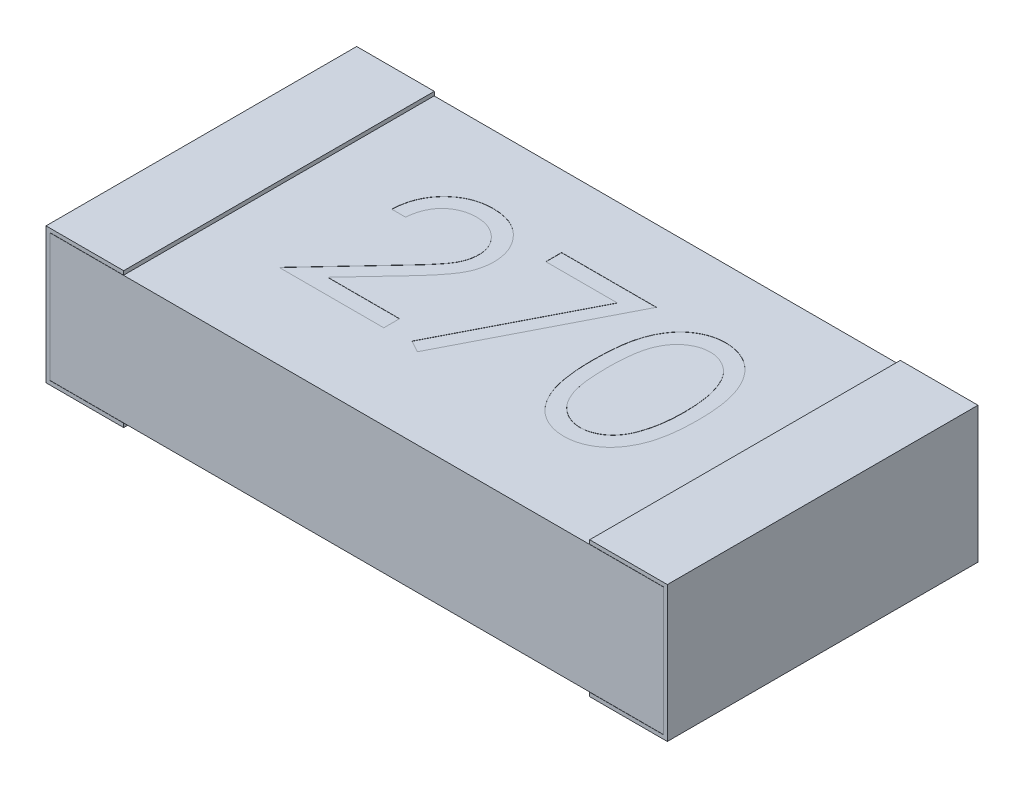
from build123d import *

# Parameters (mm, degrees)
SKETCH1_W           = 3.2
SKETCH1_H           = 1.6
BOSS_EXTRUDE1_DEPTH = 0.7
SKETCH2_W           = 2.4
SKETCH2_H           = 0.021
CUT_EXTRUDE1_DEPTH  = 4.645545227
CUT_EXTRUDE2_DEPTH  = 4.645545227
CUT_EXTRUDE3_DEPTH  = 0.001


with BuildPart() as part:
    # Sketch1 → Boss-Extrude1 (new body)
    with BuildSketch(Plane(origin=(0, 0, 0), x_dir=(1, 0, 0), z_dir=(0, 1, 0))):
        with Locations((1.6, 0.8)):
            Rectangle(SKETCH1_W, SKETCH1_H)
    extrude(amount=BOSS_EXTRUDE1_DEPTH)

    # Sketch2 → Cut-Extrude1 (cut, through all)
    with BuildSketch(Plane.XY):
        with Locations((1.6, 0.6895)):
            Rectangle(SKETCH2_W, SKETCH2_H)
        with Locations((1.6, 0.0105)):
            Rectangle(SKETCH2_W, SKETCH2_H)
    extrude(amount=-CUT_EXTRUDE1_DEPTH, mode=Mode.SUBTRACT)

    # Sketch5 → Cut-Extrude2 (cut, through all)
    with BuildSketch(Plane.XY):
        Polygon((0.02, 0.02), (0.4, 0.02), (0.4, 0.021), (0.021, 0.021), (0.021, 0.679), (0.4, 0.679), (0.4, 0.68), (0.02, 0.68), align=None)
        Polygon((3.179, 0.021), (2.8, 0.021), (2.8, 0.02), (3.18, 0.02), (3.18, 0.68), (2.8, 0.68), (2.8, 0.679), (3.179, 0.679), align=None)
    extrude(amount=-CUT_EXTRUDE2_DEPTH, mode=Mode.SUBTRACT)


with BuildPart() as cut_extrude2_piece_1:
    # of the separate pieces the step leaves, piece 1, a body of its own (cut_extrude2_pieces)
    add(part.part.solids().sort_by_distance((3.179, 0.679, 0))[0])

    # Sketch6 → Cut-Extrude3 (cut)
    with BuildSketch(Plane(origin=(0, 0.679, 0), x_dir=(1, 0, 0), z_dir=(0, 1, 0))):
        with BuildLine():
            Line((0.866030363, 0.985569169), (0.794796388, 0.985569169))
            add(Edge.make_bspline(
                [(0.794796388, 0.985569169), (0.795260653, 0.995019531), (0.796172458, 1.013579791), (0.800442445, 1.040640748), (0.806552251, 1.066506747), (0.815190848, 1.090970102), (0.825919236, 1.114247118), (0.838784796, 1.136245336), (0.854023402, 1.156880837), (0.871306, 1.175962325), (0.890076745, 1.193467363), (0.910330056, 1.20858382), (0.931612768, 1.221355864), (0.95386031, 1.232033217), (0.977323688, 1.240047789), (1.001789979, 1.245994482), (1.027366676, 1.249572332), (1.044792895, 1.249956912), (1.053655563, 1.250152502)],
                knots=[0, 0, 0, 0, 1.10065271, 2.161652631, 3.183658789, 4.190468796, 5.17591951, 6.163126047, 7.15150782, 8.156236427, 9.156009102, 10.134482811, 11.092018607, 12.041330605, 13.001268258, 13.972401359, 14.968799086, 16, 16, 16, 16], degree=3))
            add(Edge.make_bspline(
                [(1.053655563, 1.250152502), (1.062359162, 1.249948745), (1.079461423, 1.24954837), (1.104421916, 1.246110065), (1.128183909, 1.240724904), (1.150700956, 1.233169444), (1.171793403, 1.223012975), (1.191619701, 1.210812462), (1.210415885, 1.196701893), (1.227335637, 1.180088975), (1.242872291, 1.162353791), (1.256275838, 1.143419927), (1.26775418, 1.123864357), (1.277321744, 1.103537961), (1.284364832, 1.082249353), (1.289712033, 1.06030847), (1.2927345, 1.0374882), (1.293198373, 1.022042606), (1.293434209, 1.014189962)],
                knots=[0, 0, 0, 0, 1.111607364, 2.184268762, 3.212621178, 4.221274766, 5.211760367, 6.196651075, 7.1921475, 8.207485113, 9.220403448, 10.201281604, 11.166441695, 12.114753415, 13.065576456, 14.026450734, 14.996634279, 16, 16, 16, 16], degree=3))
            add(Edge.make_bspline(
                [(1.293434209, 1.014189962), (1.293050201, 1.00313465), (1.292288924, 0.98121803), (1.285776914, 0.949011088), (1.275606366, 0.917806866), (1.263360537, 0.892693228), (1.251006965, 0.872456346), (1.239874619, 0.855794694), (1.226842421, 0.837854703), (1.21172069, 0.81869645), (1.194822235, 0.79816987), (1.175993994, 0.776287363), (1.155101705, 0.753275015), (1.140438081, 0.737557495), (1.132839758, 0.729413069)],
                knots=[0, 0, 0, 0, 1.184426356, 2.348067706, 3.509069118, 4.696110526, 5.333549288, 6.050745305, 6.844228056, 7.710549037, 8.667450064, 9.695053472, 10.805634456, 12, 12, 12, 12], degree=3))
            Line((1.132839758, 0.729413069), (0.934243253, 0.517460195))
            Line((0.934243253, 0.517460195), (1.303610491, 0.517460195))
            Line((1.303610491, 0.517460195), (1.303610491, 0.436049938))
            Line((1.303610491, 0.436049938), (0.764267542, 0.436049938))
            Line((0.764267542, 0.436049938), (1.072100074, 0.764553043))
            add(Edge.make_bspline(
                [(1.072100074, 0.764553043), (1.079594863, 0.772376766), (1.093990818, 0.787404537), (1.114352224, 0.809344459), (1.132639994, 0.829698372), (1.14897251, 0.848427822), (1.162995466, 0.865806766), (1.175439704, 0.881272351), (1.185410472, 0.895504164), (1.196231642, 0.912000696), (1.206712313, 0.932142061), (1.215718508, 0.956755951), (1.22121009, 0.982094096), (1.221868865, 0.999216879), (1.222200235, 1.007829786)],
                knots=[0, 0, 0, 0, 1.329631726, 2.553950428, 3.673215718, 4.687767853, 5.603093632, 6.413772471, 7.123043292, 7.734684054, 8.834405432, 9.900288307, 10.943827018, 12, 12, 12, 12], degree=3))
            add(Edge.make_bspline(
                [(1.222200235, 1.007829786), (1.222056057, 1.013245746), (1.221771912, 1.023919563), (1.219264184, 1.039569084), (1.21547448, 1.054665032), (1.210044037, 1.069253844), (1.20287608, 1.08318884), (1.194150867, 1.096486983), (1.184083835, 1.109343231), (1.172438101, 1.121397639), (1.159644774, 1.132437841), (1.146129649, 1.142217768), (1.131830786, 1.150390923), (1.116808473, 1.157090966), (1.10110459, 1.162346812), (1.084688764, 1.165988668), (1.067606353, 1.168275231), (1.055941971, 1.168584606), (1.049998462, 1.168742246)],
                knots=[0, 0, 0, 0, 0.991446411, 1.95395049, 2.89581595, 3.838931463, 4.798493298, 5.75982156, 6.748411868, 7.785213223, 8.824556874, 9.840280684, 10.836137867, 11.835679398, 12.848801643, 13.863922112, 14.911575587, 16, 16, 16, 16], degree=3))
            add(Edge.make_bspline(
                [(1.049998462, 1.168742246), (1.043791148, 1.168580087), (1.031601008, 1.168261633), (1.013703299, 1.166033993), (0.99662956, 1.162190919), (0.980336843, 1.15693478), (0.96479758, 1.150254002), (0.950087341, 1.141932839), (0.93623915, 1.132003368), (0.923226974, 1.120745599), (0.911238179, 1.108211696), (0.900704691, 1.094239437), (0.891500817, 1.079083934), (0.883470508, 1.06278608), (0.876949129, 1.045197991), (0.871965932, 1.026382101), (0.868022844, 1.006420109), (0.866705554, 0.99263492), (0.866030363, 0.985569169)],
                knots=[0, 0, 0, 0, 1.031018746, 2.02475058, 2.990194455, 3.934040569, 4.864654155, 5.795059489, 6.735614925, 7.690564532, 8.649604399, 9.611025574, 10.590972636, 11.591080095, 12.624614302, 13.701020113, 14.821632451, 16, 16, 16, 16], degree=3))
        make_face()
        Polygon((1.425725876, 1.229799938), (1.914187414, 1.229799938), (1.49695985, 0.415697374), (1.435425144, 0.449565313), (1.793662074, 1.148389682), (1.425725876, 1.148389682), align=None)
        with BuildLine():
            add(Edge.make_bspline(
                [(1.985421388, 0.832606929), (1.985495778, 0.845329016), (1.985640282, 0.870041851), (1.987247834, 0.90605194), (1.989918314, 0.939834005), (1.993578039, 0.971389665), (1.998031653, 1.000727065), (2.00397695, 1.027767805), (2.010738068, 1.052637037), (2.018574069, 1.075415859), (2.027415943, 1.096411159), (2.037039427, 1.11601116), (2.047826443, 1.134186206), (2.059160493, 1.151226383), (2.071500373, 1.166852757), (2.08449492, 1.181286003), (2.09865131, 1.194192548), (2.113488314, 1.205950549), (2.129140262, 1.21625784), (2.14516101, 1.225336693), (2.161660828, 1.233092735), (2.178684766, 1.239191101), (2.19607981, 1.244228204), (2.21390677, 1.24767284), (2.23219508, 1.249840211), (2.244539351, 1.250047418), (2.250799744, 1.250152502)],
                knots=[0, 0, 0, 0, 1.646270934, 3.197905019, 4.663502075, 6.030701355, 7.308322542, 8.50163776, 9.611534131, 10.641858119, 11.616356847, 12.558055219, 13.465016945, 14.349605745, 15.204443733, 16.039544428, 16.859896111, 17.680448484, 18.487036065, 19.28249412, 20.06191084, 20.843045899, 21.620316918, 22.403196591, 23.190181807, 24, 24, 24, 24], degree=3))
            add(Edge.make_bspline(
                [(2.250799744, 1.250152502), (2.257112433, 1.250041873), (2.269666385, 1.249821866), (2.288226613, 1.247707329), (2.306358058, 1.244198699), (2.323983422, 1.239227335), (2.341247481, 1.233059744), (2.358015202, 1.225329273), (2.374390737, 1.216330673), (2.390113856, 1.205757043), (2.40535717, 1.193968206), (2.419746262, 1.180641672), (2.43328244, 1.165912003), (2.44613559, 1.149936795), (2.457941056, 1.132409642), (2.469183602, 1.113635388), (2.479246546, 1.09328571), (2.48893816, 1.07170014), (2.497303601, 1.048281417), (2.50484791, 1.023161552), (2.510943677, 0.996043834), (2.516021244, 0.967070543), (2.519954818, 0.936135274), (2.522819721, 0.903304342), (2.524333081, 0.868556146), (2.524618083, 0.844798563), (2.524764337, 0.832606929)],
                knots=[0, 0, 0, 0, 0.810914788, 1.612654377, 2.396697861, 3.181598691, 3.963628158, 4.749916497, 5.551656086, 6.361998678, 7.18212741, 8.025565596, 8.878627764, 9.750805457, 10.657531673, 11.591944965, 12.560506719, 13.57287815, 14.630710178, 15.753379473, 16.941251878, 18.199788006, 19.531962791, 20.947069417, 22.433333509, 24, 24, 24, 24], degree=3))
            add(Edge.make_bspline(
                [(2.524764337, 0.832606929), (2.524616567, 0.820468472), (2.524328643, 0.796817182), (2.522836686, 0.762225336), (2.519897854, 0.729568637), (2.51622166, 0.698768764), (2.511130103, 0.669953911), (2.504869645, 0.643024367), (2.49791859, 0.617863836), (2.489338199, 0.594678441), (2.479946841, 0.573144747), (2.469728967, 0.553036304), (2.45878206, 0.534175377), (2.446855684, 0.516712935), (2.43414357, 0.500525275), (2.420373643, 0.485898136), (2.405934064, 0.472479072), (2.390645891, 0.460538435), (2.374677557, 0.45008706), (2.358358267, 0.440740348), (2.341398463, 0.433203647), (2.32418249, 0.426732308), (2.306464093, 0.421788276), (2.288265358, 0.418369741), (2.269678854, 0.415972197), (2.257114571, 0.415789299), (2.250799744, 0.415697374)],
                knots=[0, 0, 0, 0, 1.561518951, 3.042555995, 4.452378317, 5.7783523, 7.031515105, 8.214008947, 9.334062868, 10.386615937, 11.391082383, 12.354592575, 13.286541444, 14.194233754, 15.072674879, 15.931287219, 16.775624067, 17.606195743, 18.42308326, 19.229000347, 20.022332153, 20.807536673, 21.593273796, 22.3848459, 23.188221202, 24, 24, 24, 24], degree=3))
            add(Edge.make_bspline(
                [(2.250799744, 0.415697374), (2.244539525, 0.415803137), (2.232195596, 0.41601168), (2.213904778, 0.418169259), (2.196151438, 0.42163806), (2.178847971, 0.42649504), (2.1619056, 0.432440191), (2.145555192, 0.440185758), (2.12961495, 0.449106163), (2.1141274, 0.459265125), (2.099383571, 0.470904149), (2.085300494, 0.483777479), (2.072231963, 0.49820636), (2.060068517, 0.51396296), (2.048508322, 0.530902321), (2.037874482, 0.54925572), (2.028038592, 0.568950383), (2.019048014, 0.590113552), (2.011076799, 0.613054045), (2.004035623, 0.638034305), (1.998476162, 0.665274815), (1.993717528, 0.694556789), (1.989879319, 0.726006056), (1.987258963, 0.759639688), (1.985639415, 0.795436726), (1.98549539, 0.819990764), (1.985421388, 0.832606929)],
                knots=[0, 0, 0, 0, 0.810891512, 1.598919785, 2.382837074, 3.152667961, 3.926044502, 4.706494248, 5.493654104, 6.291793342, 7.103789334, 7.925228297, 8.761435821, 9.622817696, 10.50288917, 11.416980706, 12.369136599, 13.353924996, 14.394355917, 15.514179734, 16.714354668, 17.994756427, 19.357759367, 20.818452758, 22.365282078, 24, 24, 24, 24], degree=3))
        make_face()
        with BuildLine():
            add(Edge.make_bspline(
                [(2.056655363, 0.832924938), (2.056682452, 0.822323001), (2.056735026, 0.801746723), (2.058108486, 0.771846555), (2.05997952, 0.743958641), (2.062392815, 0.718047571), (2.065976698, 0.694201051), (2.069992344, 0.672255069), (2.074879143, 0.652325767), (2.080661049, 0.634276389), (2.087246701, 0.617800618), (2.094437138, 0.602469628), (2.102161623, 0.588102314), (2.110806502, 0.574827727), (2.120221526, 0.562602579), (2.130194032, 0.551210491), (2.141096208, 0.541051175), (2.156178307, 0.528866692), (2.176089293, 0.516275746), (2.201176432, 0.505311543), (2.226954813, 0.498421236), (2.244451614, 0.497544991), (2.25318481, 0.497107631)],
                knots=[0, 0, 0, 0, 1.459021318, 2.831673884, 4.118529203, 5.306027144, 6.411944654, 7.436330062, 8.375795394, 9.233974572, 10.042671642, 10.816086306, 11.563610507, 12.285937304, 12.993564865, 13.685989202, 14.367179055, 15.041617293, 16.353048772, 17.594441528, 18.799311195, 20, 20, 20, 20], degree=3))
            add(Edge.make_bspline(
                [(2.25318481, 0.497107631), (2.261974496, 0.497469984), (2.279535721, 0.498193944), (2.30519285, 0.505178658), (2.330100786, 0.515717285), (2.349620672, 0.528178595), (2.364471178, 0.540045912), (2.375111281, 0.550163877), (2.384877138, 0.561493154), (2.394139538, 0.573716745), (2.402634721, 0.587068183), (2.410359754, 0.601483267), (2.417409013, 0.617002027), (2.421425172, 0.627835521), (2.42347853, 0.633374407)],
                knots=[0, 0, 0, 0, 1.353760809, 2.704726607, 4.075137775, 5.516104923, 6.260822281, 7.007110065, 7.778089737, 8.566572457, 9.372053459, 10.217411131, 11.088608312, 12, 12, 12, 12], degree=3))
            add(Edge.make_bspline(
                [(2.42347853, 0.633374407), (2.42587152, 0.640456866), (2.430730316, 0.654837295), (2.436992272, 0.677144766), (2.441923818, 0.700549679), (2.44636051, 0.72491216), (2.449388792, 0.750411878), (2.451826243, 0.776969933), (2.453261952, 0.804606349), (2.453439923, 0.82338307), (2.453530363, 0.832924938)],
                knots=[0, 0, 0, 0, 0.884706709, 1.796334032, 2.740027952, 3.714592787, 4.726048262, 5.777819803, 6.87074269, 8, 8, 8, 8], degree=3))
            add(Edge.make_bspline(
                [(2.453530363, 0.832924938), (2.453405588, 0.842465263), (2.453161501, 0.861128177), (2.452228507, 0.888459979), (2.449819232, 0.914419632), (2.447143361, 0.939118971), (2.44319792, 0.962421272), (2.438943917, 0.984521609), (2.433228642, 1.005146188), (2.427123622, 1.024617914), (2.420136264, 1.042715563), (2.41244466, 1.059523511), (2.404230083, 1.075122904), (2.395307825, 1.089470942), (2.385783804, 1.102631894), (2.375406645, 1.114341882), (2.364587975, 1.124963837), (2.349434792, 1.137088384), (2.329596872, 1.149450858), (2.304912234, 1.160827736), (2.27922407, 1.167361045), (2.261858305, 1.168282178), (2.25318481, 1.168742246)],
                knots=[0, 0, 0, 0, 1.31362396, 2.569729283, 3.763502607, 4.902122613, 5.988968491, 7.01645872, 7.998833611, 8.933434873, 9.825090667, 10.667526885, 11.477055099, 12.250526234, 12.991942729, 13.710640831, 14.402115721, 15.076753259, 16.378508321, 17.609869233, 18.806226677, 20, 20, 20, 20], degree=3))
            add(Edge.make_bspline(
                [(2.25318481, 1.168742246), (2.244405801, 1.168281543), (2.226831789, 1.167359297), (2.200876628, 1.160852077), (2.175997248, 1.149509851), (2.156211788, 1.137047438), (2.141048036, 1.125177857), (2.130370354, 1.114884857), (2.120358633, 1.103625796), (2.111135779, 1.091288219), (2.102497674, 1.078029109), (2.09456448, 1.063744157), (2.0874168, 1.048360973), (2.080820842, 1.031892602), (2.075021299, 1.013844781), (2.07023749, 0.993940027), (2.065818105, 0.972063848), (2.062689535, 0.948088174), (2.05990829, 0.922170614), (2.058120913, 0.89421308), (2.056730431, 0.864262765), (2.056680887, 0.843580098), (2.056655363, 0.832924938)],
                knots=[0, 0, 0, 0, 1.207732386, 2.417664972, 3.655092373, 4.956220595, 5.625982001, 6.301752483, 6.994047911, 7.697131622, 8.419323945, 9.170223765, 9.943494443, 10.752040957, 11.610060368, 12.549350801, 13.567764191, 14.679664412, 15.874934091, 17.154273443, 18.533957287, 20, 20, 20, 20], degree=3))
        make_face(mode=Mode.SUBTRACT)
    extrude(amount=-CUT_EXTRUDE3_DEPTH, mode=Mode.SUBTRACT)


with BuildPart() as cut_extrude2_piece_2:
    # of the separate pieces the step leaves, piece 2, a body of its own (cut_extrude2_pieces)
    add(part.part.solids().sort_by_distance((2.8, 0, 0))[0])


with BuildPart() as cut_extrude2_piece_3:
    # of the separate pieces the step leaves, piece 3, a body of its own (cut_extrude2_pieces)
    add(part.part.solids().sort_by_distance((0, 0, 0))[0])


solid = Compound([cut_extrude2_piece_1.part, cut_extrude2_piece_2.part, cut_extrude2_piece_3.part])
